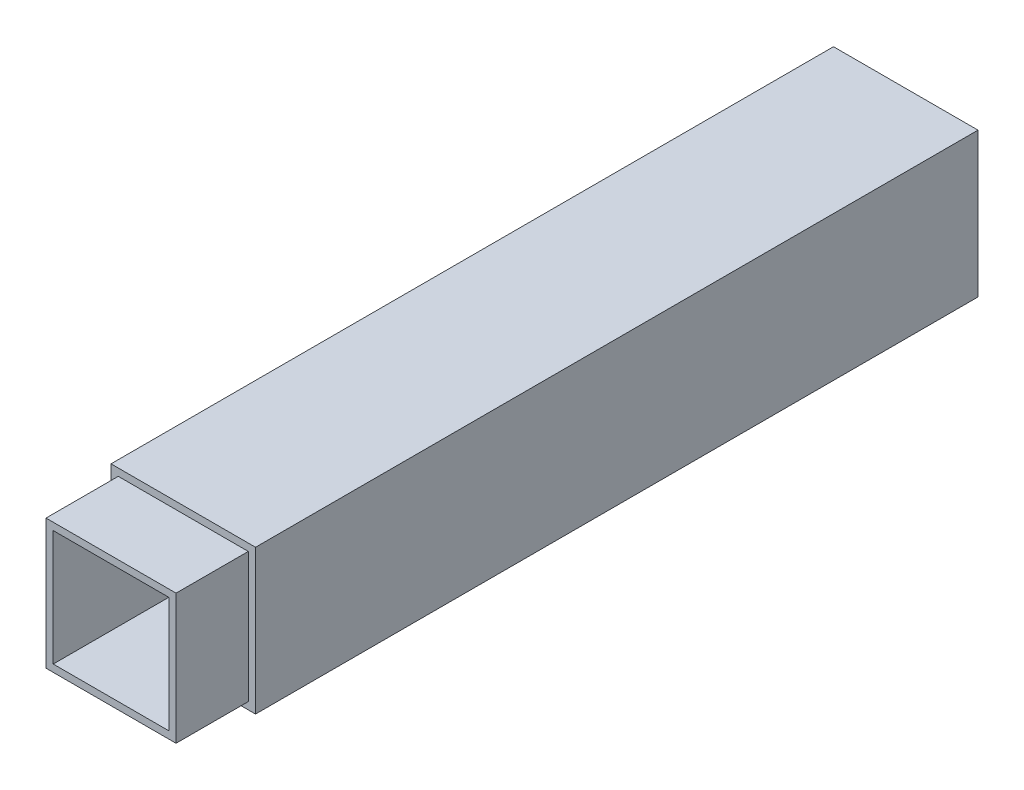
from build123d import *

# Parameters (mm, degrees)
SKETCH_1_W          = 20
SKETCH_1_H          = 20
EXTRUDE_1_DEPTH     = 100
SKETCH_3_W          = 18
SKETCH_3_H          = 18
EXTRUDE_2_DEPTH     = 10
SKETCH_4_W          = 16
SKETCH_4_H          = 16
CUT_EXTRUDE_1_DEPTH = 100


with BuildPart() as part:
    # 草圖1 → 填料-伸長1 (new body)
    with BuildSketch(Plane.XY):
        Rectangle(SKETCH_1_W, SKETCH_1_H)
    extrude(amount=EXTRUDE_1_DEPTH)

    # 草圖3 → 填料-伸長2 (add)
    with BuildSketch(Plane.XY.offset(100)):
        Rectangle(SKETCH_3_W, SKETCH_3_H)
    extrude(amount=EXTRUDE_2_DEPTH)

    # 草圖4 → 除料-伸長1 (cut)
    with BuildSketch(Plane.XY.offset(110)):
        Rectangle(SKETCH_4_W, SKETCH_4_H)
    extrude(amount=-CUT_EXTRUDE_1_DEPTH, mode=Mode.SUBTRACT)


solid = part.part
